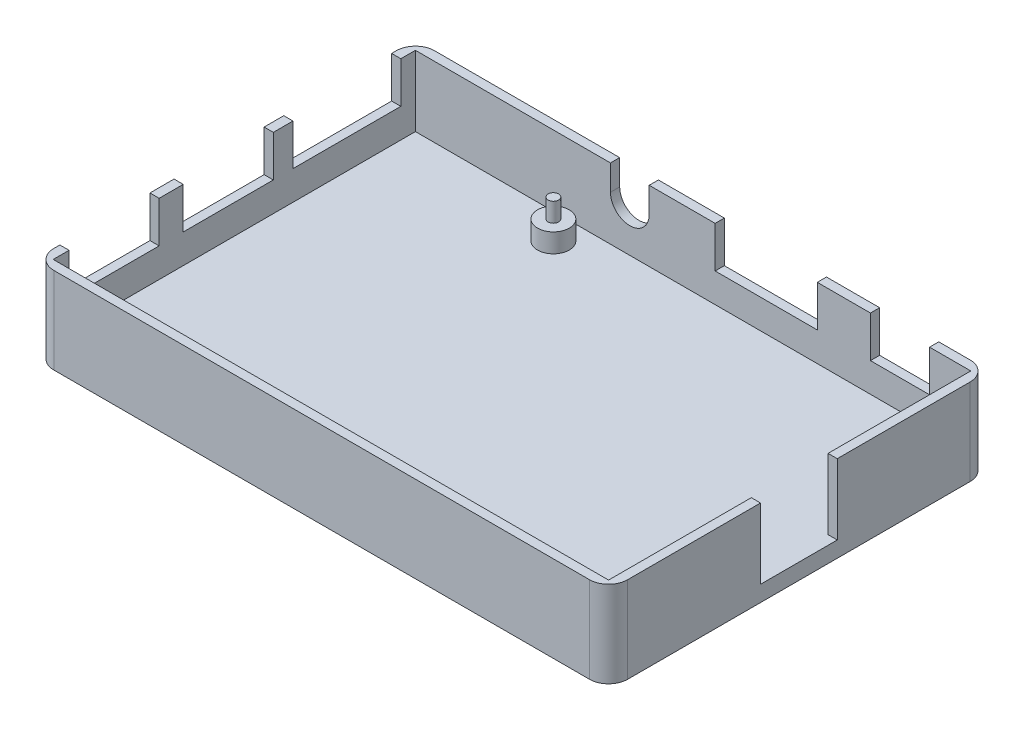
from build123d import *

# Parameters (mm, degrees)
CROQUIS1_W              = 89
CROQUIS1_H              = 60
SALIENTE_EXTRUIR1_DEPTH = 2.5
CROQUIS2_R              = 2.5
SALIENTE_EXTRUIR2_DEPTH = 3
CROQUIS3_R              = 0.83
SALIENTE_EXTRUIR3_DEPTH = 3
CROQUIS4_W              = 89
CROQUIS4_H              = 1.45
SALIENTE_EXTRUIR4_DEPTH = 11.1
CROQUIS5_W              = 1.45
CROQUIS5_H              = 60
SALIENTE_EXTRUIR5_DEPTH = 13.6
CORTAR_EXTRUIR1_REACH   = 62
CORTAR_EXTRUIR2_REACH   = 62
CROQUIS7_W              = 16.1
CROQUIS7_H              = 6.5
CORTAR_EXTRUIR3_REACH   = 62
CROQUIS8_W              = 9.32
CROQUIS8_H              = 6.5
REDONDEO1_R             = 3
CROQUIS12_W             = 1.45
CROQUIS12_H             = 57.1
SALIENTE_EXTRUIR7_DEPTH = 11.1
CORTAR_EXTRUIR5_REACH   = 92.45
CROQUIS13_W             = 17
CROQUIS13_H             = 6.5
CORTAR_EXTRUIR6_REACH   = 92.45
CROQUIS14_W             = 14.2
CROQUIS14_H             = 6.5
REDONDEO2_R             = 3
CROQUIS15_W             = 1.45
CROQUIS15_H             = 12.1
CORTAR_EXTRUIR7_DEPTH   = 11.1


with BuildPart() as part:
    # Croquis1 → Saliente-Extruir1 (new body)
    with BuildSketch(Plane(origin=(0, 0, 0), x_dir=(1, 0, 0), z_dir=(0, 1, 0))):
        Rectangle(CROQUIS1_W, CROQUIS1_H)
    extrude(amount=-SALIENTE_EXTRUIR1_DEPTH)

    # Croquis2 → Saliente-Extruir2 (add)
    with BuildSketch(Plane(origin=(0, 0, 0), x_dir=(1, 0, 0), z_dir=(0, 1, 0))):
        with Locations((40.75, 24.5)):
            Circle(CROQUIS2_R)
        with Locations((40.75, -24.5)):
            Circle(CROQUIS2_R)
        with Locations((-17.25, 24.5)):
            Circle(CROQUIS2_R)
        with Locations((-17.25, -24.5)):
            Circle(CROQUIS2_R)
    extrude(amount=SALIENTE_EXTRUIR2_DEPTH)

    # Croquis3 → Saliente-Extruir3 (add)
    with BuildSketch(Plane(origin=(0, 3, 0), x_dir=(1, 0, 0), z_dir=(0, 1, 0))):
        with Locations((-17.25, 24.5)):
            Circle(CROQUIS3_R)
        with Locations((40.75, 24.5)):
            Circle(CROQUIS3_R)
        with Locations((40.75, -24.5)):
            Circle(CROQUIS3_R)
        with Locations((-17.25, -24.5)):
            Circle(CROQUIS3_R)
    extrude(amount=SALIENTE_EXTRUIR3_DEPTH)

    # Croquis4 → Saliente-Extruir4 (add)
    with BuildSketch(Plane(origin=(0, 0, 0), x_dir=(1, 0, 0), z_dir=(0, 1, 0))):
        with Locations((0, -29.275)):
            Rectangle(CROQUIS4_W, CROQUIS4_H)
        with Locations((0, 29.275)):
            Rectangle(CROQUIS4_W, CROQUIS4_H)
    extrude(amount=SALIENTE_EXTRUIR4_DEPTH)

    # Croquis5 → Saliente-Extruir5 (add)
    with BuildSketch(Plane.XZ.offset(2.5)):
        with Locations((45.225, 0)):
            Rectangle(CROQUIS5_W, CROQUIS5_H)
    extrude(amount=-SALIENTE_EXTRUIR5_DEPTH)

    # Croquis6 → Cortar-Extruir1 (cut, up to next)
    with BuildSketch(Plane(origin=(0, 0, -30), x_dir=(-1, 0, 0), z_dir=(0, 0, -1)), mode=Mode.PRIVATE) as cortar_extruir1_sk1:
        with BuildLine():
            Line((6.2, 7.1), (6.2, 11.1))
            Line((6.2, 11.1), (12.3, 11.1))
            Line((12.3, 11.1), (12.3, 7.1))
            ThreePointArc((12.3, 7.1), (9.25, 4.05), (6.2, 7.1))
        make_face()
    cortar_extruir1_tool1 = extrude(cortar_extruir1_sk1.sketch, amount=-CORTAR_EXTRUIR1_REACH, mode=Mode.PRIVATE) & part.part
    add(cortar_extruir1_tool1.solids().sort_by_distance((-9.25, 7.866038, -30))[0], mode=Mode.SUBTRACT)

    # Croquis7 → Cortar-Extruir2 (cut, up to next)
    with BuildSketch(Plane(origin=(0, 0, -30), x_dir=(-1, 0, 0), z_dir=(0, 0, -1)), mode=Mode.PRIVATE) as cortar_extruir2_sk1:
        with Locations((-12.25, 7.85)):
            Rectangle(CROQUIS7_W, CROQUIS7_H)
    cortar_extruir2_tool1 = extrude(cortar_extruir2_sk1.sketch, amount=-CORTAR_EXTRUIR2_REACH, mode=Mode.PRIVATE) & part.part
    add(cortar_extruir2_tool1.solids().sort_by_distance((12.25, 7.85, -30))[0], mode=Mode.SUBTRACT)

    # Croquis8 → Cortar-Extruir3 (cut, up to next)
    with BuildSketch(Plane(origin=(0, 0, -30), x_dir=(-1, 0, 0), z_dir=(0, 0, -1)), mode=Mode.PRIVATE) as cortar_extruir3_sk1:
        with Locations((-33.34, 7.85)):
            Rectangle(CROQUIS8_W, CROQUIS8_H)
    cortar_extruir3_tool1 = extrude(cortar_extruir3_sk1.sketch, amount=-CORTAR_EXTRUIR3_REACH, mode=Mode.PRIVATE) & part.part
    add(cortar_extruir3_tool1.solids().sort_by_distance((33.34, 7.85, -30))[0], mode=Mode.SUBTRACT)

    # Redondeo1
    redondeo1_edges = [part.edges().sort_by_distance(p)[0] for p in [
        (45.95, 4.3, 30),
        (45.95, 4.3, -30),
    ]]
    fillet(redondeo1_edges, radius=REDONDEO1_R)

    # Croquis12 → Saliente-Extruir7 (add)
    with BuildSketch(Plane(origin=(0, 0, 0), x_dir=(1, 0, 0), z_dir=(0, 1, 0))):
        with Locations((-43.775, 0)):
            Rectangle(CROQUIS12_W, CROQUIS12_H)
    extrude(amount=SALIENTE_EXTRUIR7_DEPTH)

    # Croquis13 → Cortar-Extruir5 (cut, up to next)
    with BuildSketch(Plane.ZY.offset(44.5), mode=Mode.PRIVATE) as cortar_extruir5_sk1:
        with Locations((-17.75, 7.85)):
            Rectangle(CROQUIS13_W, CROQUIS13_H)
    cortar_extruir5_tool1 = extrude(cortar_extruir5_sk1.sketch, amount=-CORTAR_EXTRUIR5_REACH, mode=Mode.PRIVATE) & part.part
    add(cortar_extruir5_tool1.solids().sort_by_distance((-44.5, 7.85, -17.75))[0], mode=Mode.SUBTRACT)

    # Croquis14 → Cortar-Extruir6 (cut, up to next)
    with BuildSketch(Plane.ZY.offset(44.5), mode=Mode.PRIVATE) as cortar_extruir6_sk1:
        with Locations((0.95, 7.85)):
            Rectangle(CROQUIS14_W, CROQUIS14_H)
    cortar_extruir6_tool1 = extrude(cortar_extruir6_sk1.sketch, amount=-CORTAR_EXTRUIR6_REACH, mode=Mode.PRIVATE) & part.part
    add(cortar_extruir6_tool1.solids().sort_by_distance((-44.5, 7.85, 0.95))[0], mode=Mode.SUBTRACT)
    # Croquis14 → Cortar-Extruir6 (cut, up to next)
    with BuildSketch(Plane.ZY.offset(44.5), mode=Mode.PRIVATE) as cortar_extruir6_sk2:
        with Locations((18.95, 7.85)):
            Rectangle(CROQUIS14_W, CROQUIS14_H)
    cortar_extruir6_tool2 = extrude(cortar_extruir6_sk2.sketch, amount=-CORTAR_EXTRUIR6_REACH, mode=Mode.PRIVATE) & part.part
    add(cortar_extruir6_tool2.solids().sort_by_distance((-44.5, 7.85, 18.95))[0], mode=Mode.SUBTRACT)

    # Redondeo2
    redondeo2_edges = [part.edges().sort_by_distance(p)[0] for p in [
        (-44.5, 4.3, 30),
        (-44.5, 4.3, -30),
    ]]
    fillet(redondeo2_edges, radius=REDONDEO2_R)

    # Croquis15 → Cortar-Extruir7 (cut)
    with BuildSketch(Plane(origin=(0, 11.1, 0), x_dir=(1, 0, 0), z_dir=(0, 1, 0))):
        with Locations((45.225, 0)):
            Rectangle(CROQUIS15_W, CROQUIS15_H)
    extrude(amount=-CORTAR_EXTRUIR7_DEPTH, mode=Mode.SUBTRACT)


solid = part.part
